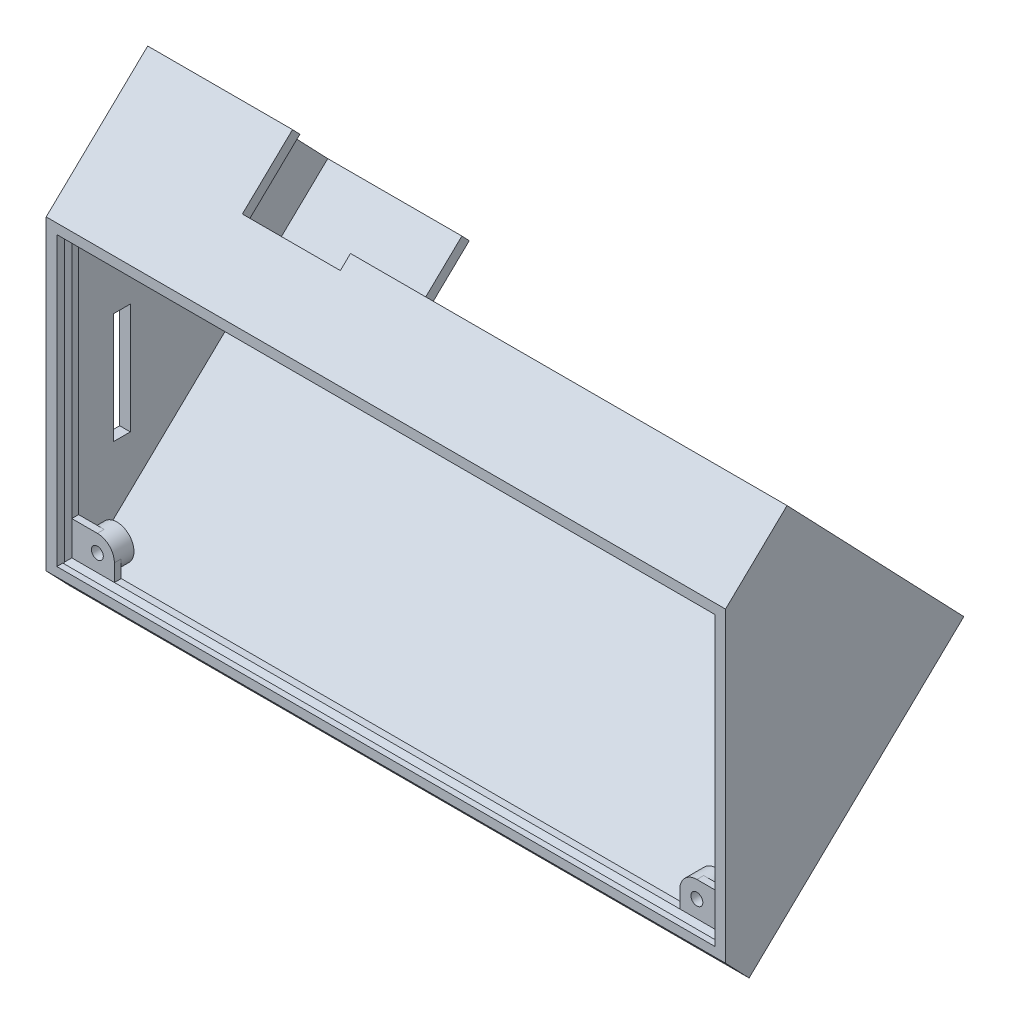
from build123d import *

# Parameters (mm, degrees)
BOSS_EXTRUDE3_DEPTH = 159.5
SHELL1_T            = -2.5
SKETCH1_W           = 154.5
SKETCH1_H           = 67.5
CUT_EXTRUDE2_DEPTH  = 4
CUT_EXTRUDE1_REACH  = 161.5
SKETCH2_W           = 4
SKETCH2_H           = 26
SKETCH8_W           = 179.5
SKETCH8_H           = 111.610999554
SKETCH8_W_2         = 159.5
SKETCH8_H_2         = 91.610999554
CUT_EXTRUDE3_DEPTH  = 56.944109771
SKETCH10_W          = 31.5
SKETCH10_H          = 55
CUT_EXTRUDE4_DEPTH  = 2.5
BOSS_EXTRUDE4_DEPTH = 13
CUT_EXTRUDE5_DEPTH  = 3.302
SKETCH13_R          = 2.6
CUT_EXTRUDE6_DEPTH  = 2.5
BOSS_EXTRUDE5_DEPTH = 1.6
SKETCH15_R          = 4
SKETCH15_R_2        = 1.4
BOSS_EXTRUDE6_DEPTH = 3
CUT_EXTRUDE7_REACH  = 6.236
SKETCH15_2_R        = 1.4


with BuildPart() as part:
    # Sketch3 → Boss-Extrude3 (new body)
    with BuildSketch(Plane.YZ.offset(-81.169946448)):
        Polygon((37, 0), (50.833221776, -14.444444444), (7.499888442, -55.944109771), (-40.777777778, -5.53328871), (-35, 0), align=None)
    extrude(amount=BOSS_EXTRUDE3_DEPTH)

    # Shell1
    shell1_openings = [part.faces().sort_by_distance(p)[0] for p in [
        (-1.419946448, 1, 0),
    ]]
    offset(amount=SHELL1_T, openings=shell1_openings, kind=Kind.INTERSECTION)

    # Sketch1 → Cut-Extrude2 (cut)
    with BuildSketch(Plane.XY):
        with Locations((-1.419946448, 0.902066229)):
            Rectangle(SKETCH1_W, SKETCH1_H)
    extrude(amount=-CUT_EXTRUDE2_DEPTH, mode=Mode.SUBTRACT)

    # Sketch2 → Cut-Extrude1 (cut, up to next)
    with BuildSketch(Plane.ZY.offset(81.169946448), mode=Mode.PRIVATE) as cut_extrude1_sk1:
        with Locations((-15.25, -1.097933771)):
            Rectangle(SKETCH2_W, SKETCH2_H)
    cut_extrude1_tool1 = extrude(cut_extrude1_sk1.sketch, amount=-CUT_EXTRUDE1_REACH, mode=Mode.PRIVATE) & part.part
    add(cut_extrude1_tool1.solids().sort_by_distance((-81.169946, -1.097934, -15.25))[0], mode=Mode.SUBTRACT)

    # Sweep1: sweep along a path in Sketch6
    with BuildLine(Plane.XY.offset(-1.8)) as sweep1_path:
        Line((-78.669946448, 34.652066229), (75.830053552, 34.652066229))
        Line((75.830053552, 34.652066229), (75.830053552, -32.847933771))
        Line((75.830053552, -32.847933771), (-78.669946448, -32.847933771))
        Line((-78.669946448, -32.847933771), (-78.669946448, 34.652066229))
    # Sketch7 → Sweep1 (sweep)
    with BuildSketch(Plane.ZY.offset(-75.830053552)):
        Polygon((-1.356838972, 35.114808383), (-2.636411987, 33.778697272), (-4.236411987, 33.778697272), (-4.236411987, 37.872531068), align=None)
    sweep(path=sweep1_path.line, transition=Transition.RIGHT)

    # Sketch8 → Cut-Extrude3 (cut, through all)
    with BuildSketch(Plane.XY):
        with Locations((-1.419946448, 5.027721999)):
            Rectangle(SKETCH8_W, SKETCH8_H)
        with Locations((-1.419946448, 5.027721999)):
            Rectangle(SKETCH8_W_2, SKETCH8_H_2, mode=Mode.SUBTRACT)
    extrude(amount=-CUT_EXTRUDE3_DEPTH, mode=Mode.SUBTRACT)

    # Sketch10 → Cut-Extrude4 (cut)
    with BuildSketch(Plane(origin=(0, 31.533839059, -32.927165761), x_dir=(-1, 0, 0), z_dir=(0, 0.691661089, -0.722222222))):
        with Locations((62.919946448, -3.277777778)):
            Rectangle(SKETCH10_W, SKETCH10_H)
    extrude(amount=-CUT_EXTRUDE4_DEPTH, mode=Mode.SUBTRACT)

    # Sketch10_3 → Boss-Extrude4 (add)
    with BuildSketch(Plane(origin=(0, 31.533839059, -32.927165761), x_dir=(-1, 0, 0), z_dir=(0, 0.691661089, -0.722222222))):
        Polygon((78.669946448, 24.222222222), (78.669946448, -30.777777778), (47.169946448, -30.777777778), (47.169946448, -33.277777778), (81.169946448, -33.277777778), (81.169946448, 26.722222222), (47.169946448, 26.722222222), (47.169946448, 24.222222222), align=None)
    extrude(amount=BOSS_EXTRUDE4_DEPTH)

    # Sketch12 → Cut-Extrude5 (cut)
    with BuildSketch(Plane(origin=(0, 31.533839059, -32.927165761), x_dir=(-1, 0, 0), z_dir=(0, 0.691661089, -0.722222222))):
        Polygon((47.169946448, -33.277777778), (-15.830053552, -33.277777778), (-15.830053552, -13.277777778), (24.169946448, 26.722222222), (47.169946448, 26.722222222), align=None)
    extrude(amount=-CUT_EXTRUDE5_DEPTH, mode=Mode.SUBTRACT)

    # Sketch13 → Cut-Extrude6 (cut)
    with BuildSketch(Plane(origin=(0, 31.533839059, -32.927165761), x_dir=(-1, 0, 0), z_dir=(0, 0.691661089, -0.722222222))):
        with Locations((-68.330053552, -23.277777778)):
            Circle(SKETCH13_R)
        with Locations((-33.330053552, -23.277777778)):
            Circle(SKETCH13_R)
        with Locations((-33.330053552, 16.722222222)):
            Circle(SKETCH13_R)
        with Locations((1.669946448, 16.722222222)):
            Circle(SKETCH13_R)
        with Locations((-68.330053552, 16.722222222)):
            Circle(SKETCH13_R)
    extrude(amount=-CUT_EXTRUDE6_DEPTH, mode=Mode.SUBTRACT)

    # Sketch14 → Boss-Extrude5 (add)
    with BuildSketch(Plane(origin=(0, 0, -4.236411987), x_dir=(-1, 0, 0), z_dir=(0, 0, -1))):
        with BuildLine():
            Line((77.796577491, -31.974564814), (67.796577491, -31.974564814))
            Line((67.796577491, -31.974564814), (67.796577491, -27.974564814))
            ThreePointArc((67.796577491, -27.974564814), (68.968150366, -25.14613769), (71.796577491, -23.974564814))
            Line((71.796577491, -23.974564814), (77.796577491, -23.974564814))
            Line((77.796577491, -23.974564814), (77.796577491, -31.974564814))
        make_face()
        with BuildLine():
            Line((-74.956684595, -31.974564814), (-64.956684595, -31.974564814))
            Line((-64.956684595, -31.974564814), (-64.956684595, -27.974564814))
            ThreePointArc((-64.956684595, -27.974564814), (-66.12825747, -25.14613769), (-68.956684595, -23.974564814))
            Line((-68.956684595, -23.974564814), (-74.956684595, -23.974564814))
            Line((-74.956684595, -23.974564814), (-74.956684595, -31.974564814))
        make_face()
    extrude(amount=-BOSS_EXTRUDE5_DEPTH)

    # Sketch15 → Boss-Extrude6 (add)
    with BuildSketch(Plane(origin=(0, 0, -4.236411987), x_dir=(-1, 0, 0), z_dir=(0, 0, -1))):
        with Locations((71.796577491, -27.974564814)):
            Circle(SKETCH15_R)
        with Locations((71.796577491, -27.974564814)):
            Circle(SKETCH15_R_2, mode=Mode.SUBTRACT)
        with Locations((-68.956684595, -27.974564814)):
            Circle(SKETCH15_R)
        with Locations((-68.956684595, -27.974564814)):
            Circle(SKETCH15_R_2, mode=Mode.SUBTRACT)
    extrude(amount=BOSS_EXTRUDE6_DEPTH)

    # Sketch15_2 → Cut-Extrude7 (cut, up to next)
    with BuildSketch(Plane(origin=(0, 0, -4.236411987), x_dir=(-1, 0, 0), z_dir=(0, 0, -1)), mode=Mode.PRIVATE) as cut_extrude7_sk1:
        with Locations((71.796577491, -27.974564814)):
            Circle(SKETCH15_2_R)
    cut_extrude7_tool1 = extrude(cut_extrude7_sk1.sketch, amount=-CUT_EXTRUDE7_REACH, mode=Mode.PRIVATE) & part.part
    add(cut_extrude7_tool1.solids().sort_by_distance((-71.796577, -27.974565, -4.236412))[0], mode=Mode.SUBTRACT)
    # Sketch15_2 → Cut-Extrude7 (cut, up to next)
    with BuildSketch(Plane(origin=(0, 0, -4.236411987), x_dir=(-1, 0, 0), z_dir=(0, 0, -1)), mode=Mode.PRIVATE) as cut_extrude7_sk2:
        with Locations((-68.956684595, -27.974564814)):
            Circle(SKETCH15_2_R)
    cut_extrude7_tool2 = extrude(cut_extrude7_sk2.sketch, amount=-CUT_EXTRUDE7_REACH, mode=Mode.PRIVATE) & part.part
    add(cut_extrude7_tool2.solids().sort_by_distance((68.956685, -27.974565, -4.236412))[0], mode=Mode.SUBTRACT)


solid = part.part
